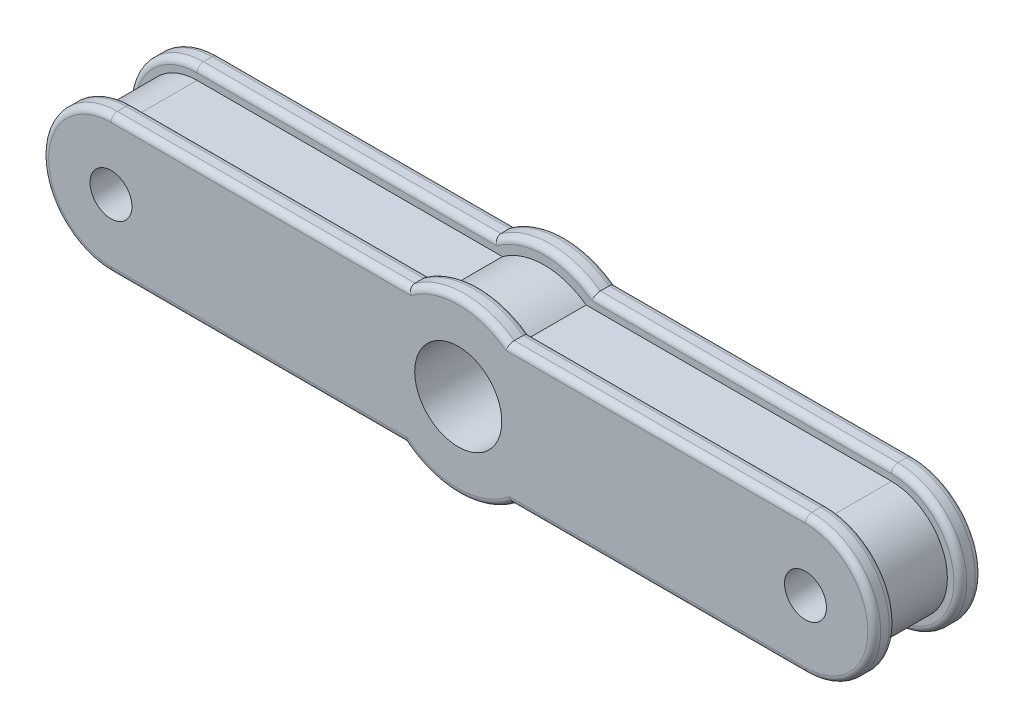
from build123d import *

# Parameters (mm, degrees)
SKETCH1_R                    = 33
BOSS_EXTRUDE1_DEPTH          = 30
BOSS_EXTRUDE4_DEPTH          = 10
FILLET2_R                    = 3
M45_TAPPED_HOLE2_D           = 40.5
M45_TAPPED_HOLE2_CSINK_D     = 45.05
M45_TAPPED_HOLE2_CSINK_ANGLE = 90
M22_TAPPED_HOLE1_D           = 19.5
M22_TAPPED_HOLE1_CSINK_D     = 22.05
M22_TAPPED_HOLE1_CSINK_ANGLE = 90


with BuildPart() as part:
    # Sketch1 → Boss-Extrude1 (new body)
    with BuildSketch(Plane.XY):
        with BuildLine():
            ThreePointArc((-21.11112511, -25.363761484), (-32.983797593, 1.033971162), (-19.481036874, 26.636238516))
            Line((-19.481036874, 26.636238516), (-161.481036874, 26.636238516))
            ThreePointArc((-161.481036874, 26.636238516), (-187.481036874, 0.636238516), (-161.481036874, -25.363761484))
            Line((-161.481036874, -25.363761484), (-21.11112511, -25.363761484))
        make_face()
        Circle(SKETCH1_R)
        with BuildLine():
            Line((161.481036874, 26.636238516), (19.481036874, 26.636238516))
            ThreePointArc((19.481036874, 26.636238516), (29.426809348, 14.93529014), (33, 0))
            ThreePointArc((33, 0), (29.880320686, -14.00594287), (21.11112511, -25.363761484))
            Line((21.11112511, -25.363761484), (161.481036874, -25.363761484))
            ThreePointArc((161.481036874, -25.363761484), (187.481036874, 0.636238516), (161.481036874, 26.636238516))
        make_face()
    extrude(amount=BOSS_EXTRUDE1_DEPTH)

    # Sketch2 → Boss-Extrude4 (add)
    with BuildSketch(Plane.XY.offset(30)):
        with BuildLine():
            Line((-161.481036874, -31.363761484), (-24.825681574, -31.363761484))
            ThreePointArc((-24.825681574, -31.363761484), (0, -40), (24.825681574, -31.363761484))
            Line((24.825681574, -31.363761484), (161.481036874, -31.363761484))
            ThreePointArc((161.481036874, -31.363761484), (193.481036874, 0.636238516), (161.481036874, 32.636238516))
            Line((161.481036874, 32.636238516), (23.127384969, 32.636238516))
            ThreePointArc((23.127384969, 32.636238516), (0, 40), (-23.127384969, 32.636238516))
            Line((-23.127384969, 32.636238516), (-161.481036874, 32.636238516))
            ThreePointArc((-161.481036874, 32.636238516), (-193.481036874, 0.636238516), (-161.481036874, -31.363761484))
        make_face()
    boss_extrude4 = extrude(amount=BOSS_EXTRUDE4_DEPTH)

    # Mirror1: Boss-Extrude4 across plane
    add(boss_extrude4.mirror(Plane.XY.offset(15)))

    # Fillet2
    fillet2_edges = [part.edges().sort_by_distance(p)[0] for p in [
        (0, -40, 30),
        (93.153359224, -31.363761484, 40),
        (193.481036874, 0.636238516, 40),
        (92.304210922, 32.636238516, 40),
        (0, 40, 30),
        (-92.304210922, 32.636238516, 30),
        (-193.481036874, 0.636238516, 30),
        (-93.153359224, -31.363761484, 30),
        (0, -40, 40),
        (0, 40, 40),
        (-92.304210922, 32.636238516, 40),
        (-193.481036874, 0.636238516, 40),
        (-93.153359224, -31.363761484, 40),
        (92.304210922, 32.636238516, 30),
        (193.481036874, 0.636238516, 30),
        (93.153359224, -31.363761484, 30),
        (0, -40, -10),
        (-93.153359224, -31.363761484, -10),
        (-193.481036874, 0.636238516, -10),
        (-92.304210922, 32.636238516, -10),
        (0, 40, -10),
        (92.304210922, 32.636238516, 0),
        (193.481036874, 0.636238516, 0),
        (93.153359224, -31.363761484, 0),
        (92.304210922, 32.636238516, -10),
        (193.481036874, 0.636238516, -10),
        (93.153359224, -31.363761484, -10),
        (0, -40, 0),
        (0, 40, 0),
        (-92.304210922, 32.636238516, 0),
        (-193.481036874, 0.636238516, 0),
        (-93.153359224, -31.363761484, 0),
    ]]
    fillet(fillet2_edges, radius=FILLET2_R)

    # M45 Tapped Hole2 (through all)
    with Locations(Plane(origin=(0, 0, -10), x_dir=(-1, 0, 0), z_dir=(0, 0, -1))):
        with Locations((0, 0)):
            CounterSinkHole(M45_TAPPED_HOLE2_D / 2, M45_TAPPED_HOLE2_CSINK_D / 2, counter_sink_angle=M45_TAPPED_HOLE2_CSINK_ANGLE)

    # M22 Tapped Hole1 (through all)
    with Locations(Plane(origin=(0, 0, -10), x_dir=(-1, 0, 0), z_dir=(0, 0, -1))):
        with Locations((-161.481036874, 0.636238516), (161.481036874, 0.636238516)):
            CounterSinkHole(M22_TAPPED_HOLE1_D / 2, M22_TAPPED_HOLE1_CSINK_D / 2, counter_sink_angle=M22_TAPPED_HOLE1_CSINK_ANGLE)


solid = part.part
